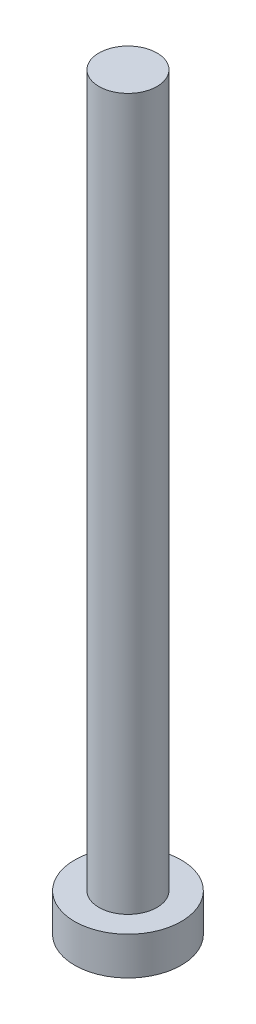
from build123d import *

# Parameters (mm, degrees)
SKETCH1_R           = 2.25
BOSS_EXTRUDE1_DEPTH = 1.6
SKETCH2_R           = 1.225
BOSS_EXTRUDE2_DEPTH = 30


with BuildPart() as part:
    # Sketch1 → Boss-Extrude1 (new body)
    with BuildSketch(Plane(origin=(0, 0, 0), x_dir=(1, 0, 0), z_dir=(0, 1, 0))):
        Circle(SKETCH1_R)
    extrude(amount=BOSS_EXTRUDE1_DEPTH)

    # Sketch2 → Boss-Extrude2 (add)
    with BuildSketch(Plane(origin=(0, 1.6, 0), x_dir=(1, 0, 0), z_dir=(0, 1, 0))):
        Circle(SKETCH2_R)
    extrude(amount=BOSS_EXTRUDE2_DEPTH)


solid = part.part
